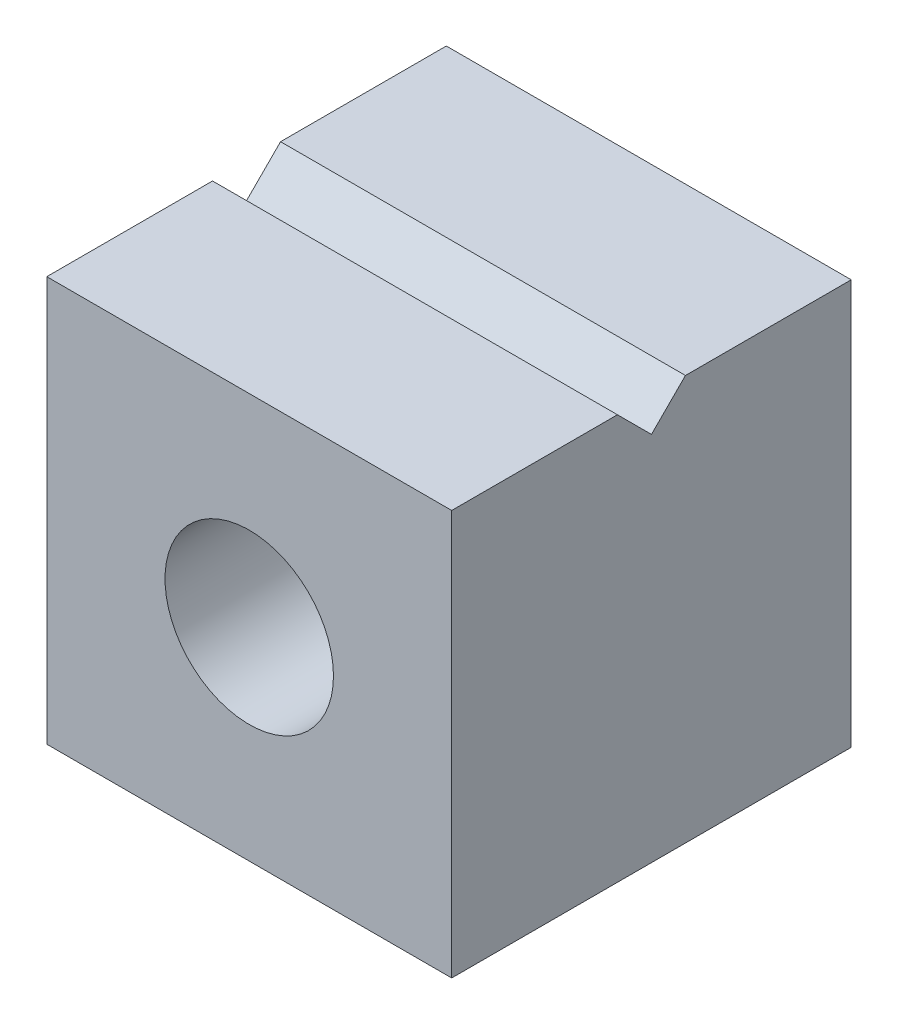
from build123d import *

# Parameters (mm, degrees)
SKETCH1_W           = 7.5
SKETCH1_H           = 7.5
SKETCH1_R           = 1.56
BOSS_EXTRUDE1_DEPTH = 7.4
CUT_EXTRUDE1_DEPTH  = 8.5


with BuildPart() as part:
    # Sketch1 → Boss-Extrude1 (new body)
    with BuildSketch(Plane.XY):
        Rectangle(SKETCH1_W, SKETCH1_H)
        Circle(SKETCH1_R, mode=Mode.SUBTRACT)
    extrude(amount=BOSS_EXTRUDE1_DEPTH)

    # Sketch2 → Cut-Extrude1 (cut, through all)
    with BuildSketch(Plane(origin=(3.75, 0, 0), x_dir=(0, 0, -1), z_dir=(1, 0, 0))):
        Polygon((-3.7, 3.12), (-4.33, 3.75), (-3.07, 3.75), align=None)
    extrude(amount=-CUT_EXTRUDE1_DEPTH, mode=Mode.SUBTRACT)


solid = part.part
